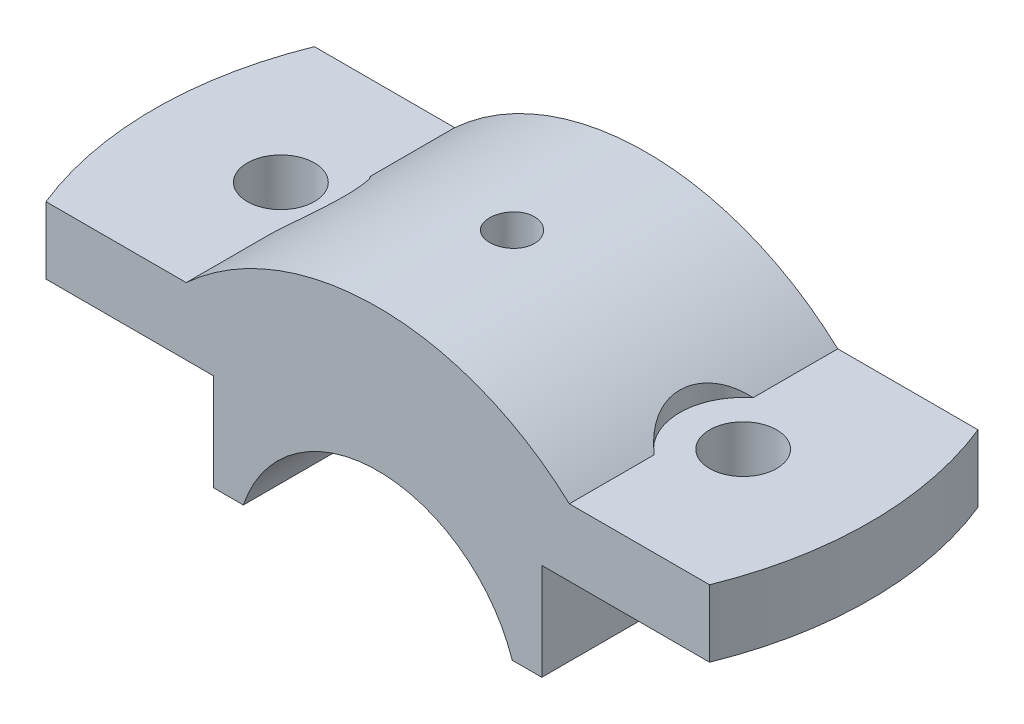
from build123d import *

# Parameters (mm, degrees)
BOSS_EXTRUDE1_DEPTH              = 457.2
F_97_0_0059_DIAMETER_HOLE1_D     = 228.6
F_97_0_0059_DIAMETER_HOLE1_DEPTH = 228.601
CUT_EXTRUDE1_DEPTH               = 66.616681
CUT_EXTRUDE2_REACH               = 560.8


with BuildPart() as part:
    # Sketch1 → Boss-Extrude1 (new body, symmetric)
    with BuildSketch(Plane.XY):
        with BuildLine():
            Line((457.905011984, 152.4), (558.8, 152.4))
            Line((558.8, 152.4), (558.8, 482.6))
            Line((558.8, 482.6), (1270, 482.6))
            Line((1270, 482.6), (1270, 711.2))
            Line((1270, 711.2), (652.537814996, 711.2))
            ThreePointArc((652.537814996, 711.2), (0, 965.2), (-652.537814996, 711.2))
            Line((-652.537814996, 711.2), (-1270, 711.2))
            Line((-1270, 711.2), (-1270, 482.6))
            Line((-1270, 482.6), (-558.8, 482.6))
            Line((-558.8, 482.6), (-558.8, 152.4))
            Line((-558.8, 152.4), (-457.905011984, 152.4))
            ThreePointArc((-457.905011984, 152.4), (0, 482.6), (457.905011984, 152.4))
        make_face()
    extrude(amount=BOSS_EXTRUDE1_DEPTH, both=True)

    # #97 (0.0059) Diameter Hole1
    with Locations(Plane(origin=(0, 711.2, 0), x_dir=(1, 0, 0), z_dir=(0, 1, 0))):
        with Locations((-787.4, 0)):
            f_97_0_0059_diameter_hole1 = Hole(F_97_0_0059_DIAMETER_HOLE1_D / 2, depth=F_97_0_0059_DIAMETER_HOLE1_DEPTH)

    # Mirror7: #97 (0.0059) Diameter Hole1 across plane
    add(f_97_0_0059_diameter_hole1.mirror(Plane(origin=(0, 0, 0), x_dir=(0, 0, 1), z_dir=(1, 0, 0))), mode=Mode.SUBTRACT)

    # Sketch5 → Cut-Extrude1 (cut)
    with BuildSketch(Plane(origin=(0, 711.2, 0), x_dir=(1, 0, 0), z_dir=(0, 1, 0))):
        with BuildLine():
            Line((-652.537814996, 168.597156133), (-652.537814996, -168.597156133))
            ThreePointArc((-652.537814996, -168.597156133), (-571.5, 0), (-652.537814996, 168.597156133))
        make_face()
    cut_extrude1 = extrude(amount=CUT_EXTRUDE1_DEPTH, mode=Mode.SUBTRACT)

    # Mirror8: Cut-Extrude1 across plane
    add(cut_extrude1.mirror(Plane(origin=(0, 0, 0), x_dir=(0, 0, 1), z_dir=(1, 0, 0))), mode=Mode.SUBTRACT)

    # Sketch6 → Cut-Extrude2 (cut, up to next)
    with BuildSketch(Plane(origin=(0, 711.2, 0), x_dir=(1, 0, 0), z_dir=(0, 1, 0)), mode=Mode.PRIVATE) as cut_extrude2_sk1:
        with BuildLine():
            Line((-1130.228649433, 457.2), (-1270, 457.2))
            Line((-1270, 457.2), (-1270, -457.2))
            Line((-1270, -457.2), (-1130.228649433, -457.2))
            ThreePointArc((-1130.228649433, -457.2), (-1219.2, 0), (-1130.228649433, 457.2))
        make_face()
    cut_extrude2_tool1 = extrude(cut_extrude2_sk1.sketch, amount=-CUT_EXTRUDE2_REACH, mode=Mode.PRIVATE) & part.part
    add(cut_extrude2_tool1.solids().sort_by_distance((-1225.646525, 711.2, 0))[0], mode=Mode.SUBTRACT)
    # Sketch6 → Cut-Extrude2 (cut, up to next)
    with BuildSketch(Plane(origin=(0, 711.2, 0), x_dir=(1, 0, 0), z_dir=(0, 1, 0)), mode=Mode.PRIVATE) as cut_extrude2_sk2:
        with BuildLine():
            Line((1130.228649433, 457.2), (1270, 457.2))
            Line((1270, 457.2), (1270, -457.2))
            Line((1270, -457.2), (1130.228649433, -457.2))
            ThreePointArc((1130.228649433, -457.2), (1219.2, 0), (1130.228649433, 457.2))
        make_face()
    cut_extrude2_tool2 = extrude(cut_extrude2_sk2.sketch, amount=-CUT_EXTRUDE2_REACH, mode=Mode.PRIVATE) & part.part
    add(cut_extrude2_tool2.solids().sort_by_distance((1225.646525, 711.2, 0))[0], mode=Mode.SUBTRACT)

    # Sketch10 → CSK for M10 Flat Head Machine Screw1 (revolve, cut)
    with BuildSketch(Plane(origin=(0, 965.2, 0), x_dir=(0, 0, 1), z_dir=(1, 0, 0))):
        Polygon((0, 0), (0, 3060.754649308), (63.5, 3022.6), (63.5, 342.9), (76.2, 330.2), (76.2, 0), align=None)
    revolve(axis=Axis((0, 971.55, 0), (0, -1, 0)), mode=Mode.SUBTRACT)


solid = part.part
